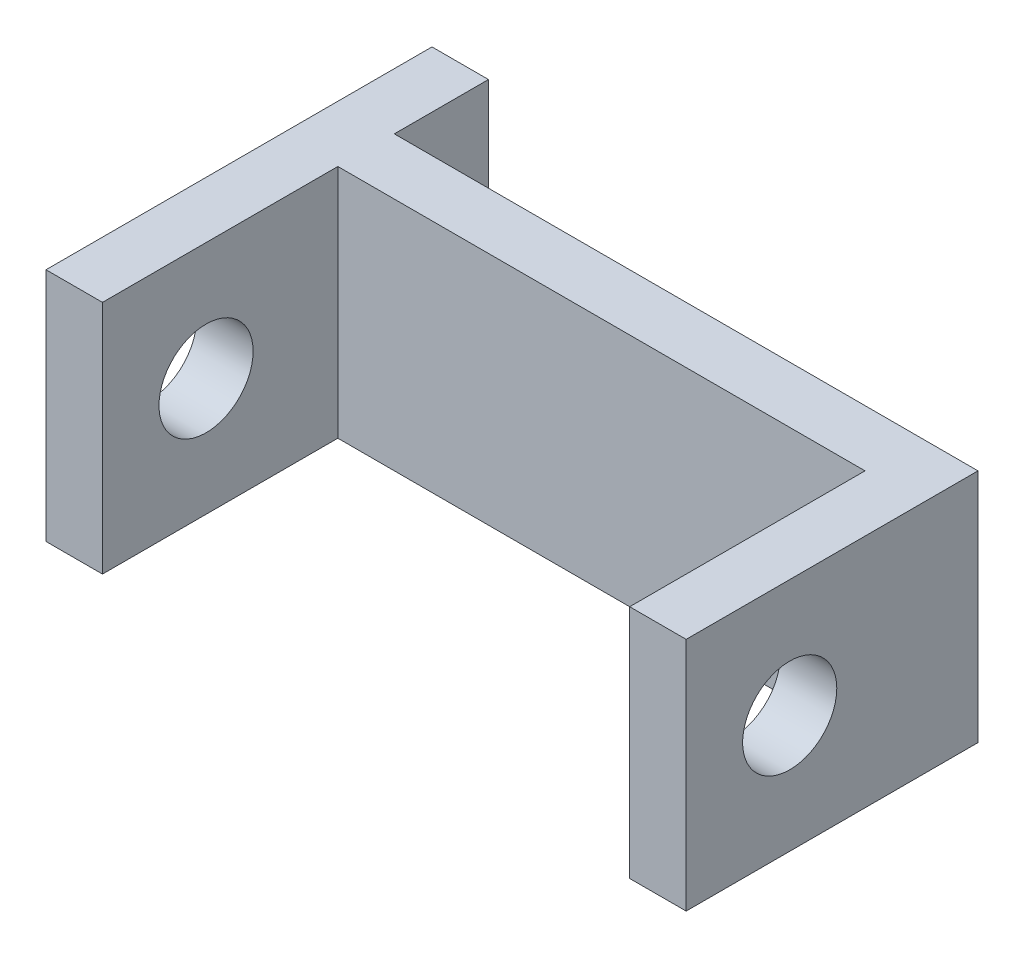
from build123d import *

# Parameters (mm, degrees)
SKETCH_1_W          = 13.6
SKETCH_1_H          = 5
EXTRUDE_1_DEPTH     = 1.2
SKETCH_2_W          = 1.2
SKETCH_2_H          = 5
EXTRUDE_2_DEPTH     = 5
SKETCH_3_R          = 1
CUT_EXTRUDE_1_DEPTH = 14
SKETCH_5_W          = 1.2
SKETCH_5_H          = 5
EXTRUDE_3_DEPTH     = 2


with BuildPart() as part:
    # 草图1 → 凸台-拉伸1 (new body)
    with BuildSketch(Plane.XY):
        with Locations((8.287992891, 2.5)):
            Rectangle(SKETCH_1_W, SKETCH_1_H)
    extrude(amount=EXTRUDE_1_DEPTH)

    # 草图2 → 凸台-拉伸2 (add)
    with BuildSketch(Plane(origin=(0, 0, 1.2), x_dir=(-1, 0, 0), z_dir=(0, 0, -1))):
        with Locations((-14.487992891, 2.5)):
            Rectangle(SKETCH_2_W, SKETCH_2_H)
        with Locations((-2.087992891, 2.5)):
            Rectangle(SKETCH_2_W, SKETCH_2_H)
    extrude(amount=-EXTRUDE_2_DEPTH)

    # 草图3 → 切除-拉伸1 (cut)
    with BuildSketch(Plane(origin=(15.087992891, 0, 0), x_dir=(0, 0, -1), z_dir=(1, 0, 0))):
        with Locations((-4, 2.5)):
            Circle(SKETCH_3_R)
    extrude(amount=-CUT_EXTRUDE_1_DEPTH, mode=Mode.SUBTRACT)

    # 草图5 → 凸台-拉伸3 (add)
    with BuildSketch(Plane(origin=(0, 0, 0), x_dir=(-1, 0, 0), z_dir=(0, 0, -1))):
        with Locations((-2.087992891, 2.5)):
            Rectangle(SKETCH_5_W, SKETCH_5_H)
    extrude(amount=EXTRUDE_3_DEPTH)


solid = part.part
